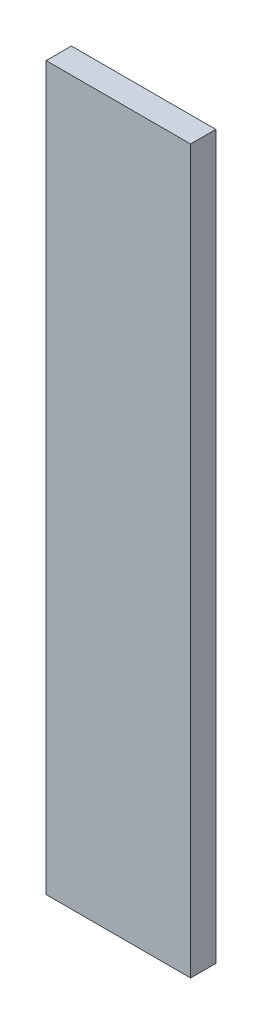
from build123d import *

# Parameters (mm, degrees)
SKETCH1_W           = 50.8
SKETCH1_H           = 254
BOSS_EXTRUDE1_DEPTH = 8.89


with BuildPart() as part:
    # Sketch1 → Boss-Extrude1 (new body)
    with BuildSketch(Plane.XY):
        with Locations((25.4, -127)):
            Rectangle(SKETCH1_W, SKETCH1_H)
    extrude(amount=BOSS_EXTRUDE1_DEPTH)


solid = part.part
